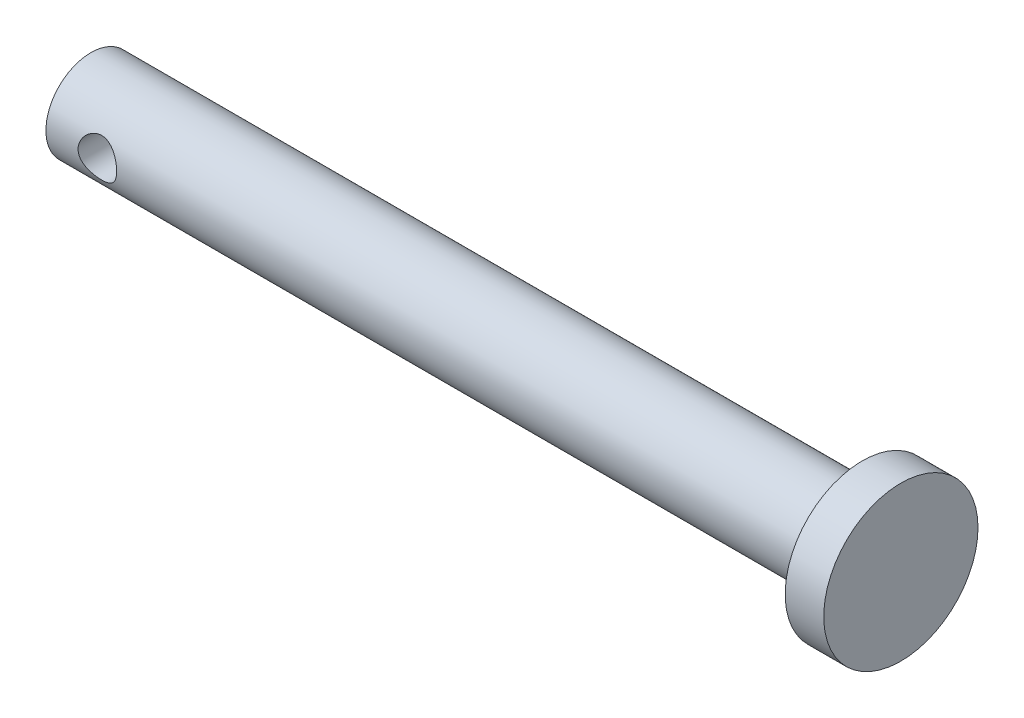
from build123d import *

# Parameters (mm, degrees)
SKETCH1_R               = 3.5
BOSS_EXTRUDE1_DEPTH     = 60
SKETCH2_R               = 6
BOSS_EXTRUDE2_DEPTH     = 3
SKETCH3_R               = 1.5
CUT_EXTRUDE1_DEPTH      = 7
CUT_EXTRUDE1_DEPTH_BACK = 7


with BuildPart() as part:
    # Sketch1 → Boss-Extrude1 (new body)
    with BuildSketch(Plane(origin=(0, 0, 0), x_dir=(0, 0, -1), z_dir=(1, 0, 0))):
        Circle(SKETCH1_R)
    extrude(amount=BOSS_EXTRUDE1_DEPTH)

    # Sketch2 → Boss-Extrude2 (add)
    with BuildSketch(Plane(origin=(60, 0, 0), x_dir=(0, 0, -1), z_dir=(1, 0, 0))):
        Circle(SKETCH2_R)
    extrude(amount=BOSS_EXTRUDE2_DEPTH)

    # Sketch3 → Cut-Extrude1 (cut, two sides)
    with BuildSketch(Plane.XY) as cut_extrude1_sk:
        with Locations((4, 0)):
            Circle(SKETCH3_R)
    extrude(amount=CUT_EXTRUDE1_DEPTH, mode=Mode.SUBTRACT)
    extrude(cut_extrude1_sk.sketch, amount=-CUT_EXTRUDE1_DEPTH_BACK, mode=Mode.SUBTRACT)


solid = part.part
